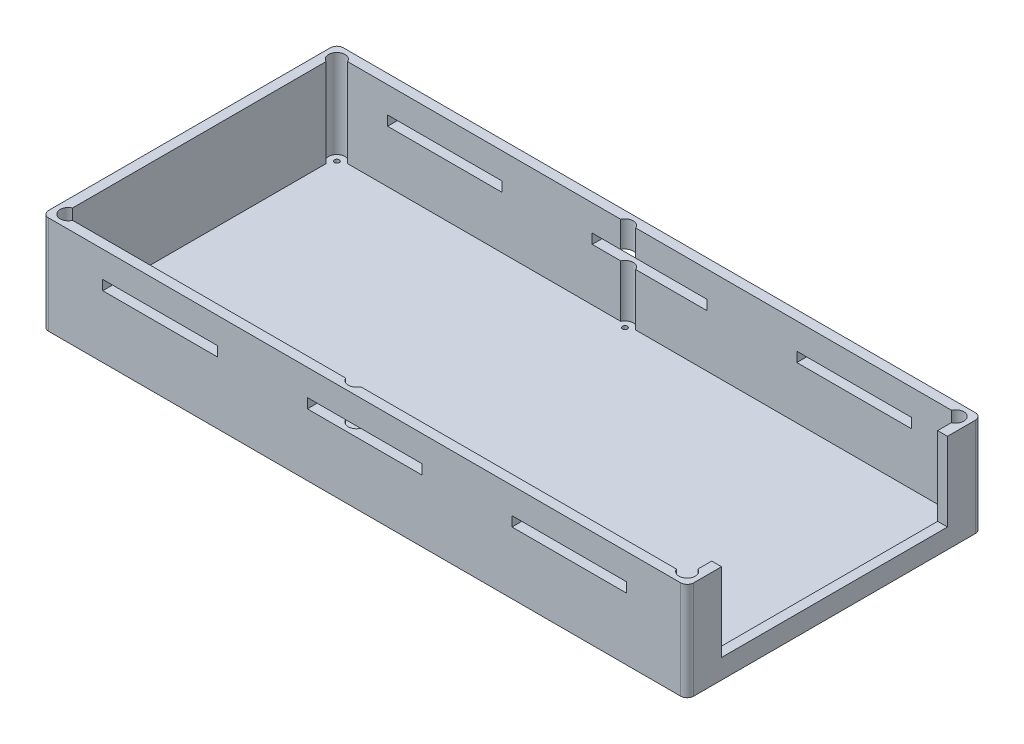
from build123d import *

# Parameters (mm, degrees)
SKETCH2_W               = 197
SKETCH2_H               = 90
BOSS_EXTRUDE1_DEPTH     = 21
SHELL1_T                = -2
SKETCH3_R               = 3.325
SKETCH3_R_2             = 1.325
BOSS_EXTRUDE2_DEPTH     = 2
SKETCH6_R               = 1.325
CUT_EXTRUDE2_DEPTH      = 3
BOSS_EXTRUDE3_DEPTH     = 19
SKETCH10_W              = 3
SKETCH10_H              = 12
CUT_EXTRUDE5_DEPTH      = 19
SKETCH12_W              = 29.592043876
SKETCH12_H              = 2
CUT_EXTRUDE6_DEPTH      = 10
CUT_EXTRUDE6_DEPTH_BACK = 73
CUT_EXTRUDE8_DEPTH      = 10
FILLET1_R               = 2
SKETCH7_R               = 6
CUT_EXTRUDE9_DEPTH      = 10
BOSS_EXTRUDE4_DEPTH     = 24
SKETCH18_W              = 191
SKETCH18_H              = 84
CUT_EXTRUDE10_DEPTH     = 21
BOSS_EXTRUDE5_DEPTH     = 19
SKETCH22_R              = 0.75
CUT_EXTRUDE11_DEPTH     = 44
SKETCH23_R              = 2
CUT_EXTRUDE12_DEPTH     = 22
SKETCH24_W              = 197
SKETCH24_H              = 24
CUT_EXTRUDE13_DEPTH     = 91
SKETCH25_R              = 0.75
BOSS_EXTRUDE9_DEPTH     = 28
BOSS_EXTRUDE10_START    = -2
BOSS_EXTRUDE10_DEPTH    = 2
BOSS_EXTRUDE11_DEPTH    = 30
SKETCH28_W              = 191
SKETCH28_H              = 84
CUT_EXTRUDE14_DEPTH     = 27
SKETCH29_R              = 0.75
CUT_EXTRUDE15_DEPTH     = 78
SKETCH30_W              = 197
SKETCH30_H              = 49
CUT_EXTRUDE16_DEPTH     = 91
SKETCH31_W              = 69
SKETCH31_H              = 24
CUT_EXTRUDE17_DEPTH     = 10
SKETCH32_R              = 2.5
CUT_EXTRUDE18_DEPTH     = 28
SKETCH33_W              = 35
SKETCH33_H              = 3
CUT_EXTRUDE19_DEPTH     = 91


with BuildPart() as part:
    # Sketch2 → Boss-Extrude1 (new body)
    with BuildSketch(Plane(origin=(0, 0, 0), x_dir=(1, 0, 0), z_dir=(0, 1, 0))):
        with Locations((98.5, 45)):
            Rectangle(SKETCH2_W, SKETCH2_H)
    extrude(amount=BOSS_EXTRUDE1_DEPTH)

    # Shell1
    shell1_openings = [part.faces().sort_by_distance(p)[0] for p in [
        (98.5, 21, -45),
    ]]
    offset(amount=SHELL1_T, openings=shell1_openings, kind=Kind.INTERSECTION)

    # Sketch3 → Boss-Extrude2 (add)
    with BuildSketch(Plane(origin=(0.486650368, 2, 38.670182975), x_dir=(1, 0, 0), z_dir=(0, 1, 0))):
        with Locations((118.948969004, 54.089521182)):
            Circle(SKETCH3_R)
        with Locations((118.948969004, 54.089521182)):
            Circle(SKETCH3_R_2, mode=Mode.SUBTRACT)
        with Locations((95.898969004, 54.089521182)):
            Circle(SKETCH3_R)
        with Locations((95.898969004, 54.089521182)):
            Circle(SKETCH3_R_2, mode=Mode.SUBTRACT)
        with Locations((95.898969004, 112.139521182)):
            Circle(SKETCH3_R)
        with Locations((95.898969004, 112.139521182)):
            Circle(SKETCH3_R_2, mode=Mode.SUBTRACT)
        with Locations((118.948969004, 112.139521182)):
            Circle(SKETCH3_R)
        with Locations((118.948969004, 112.139521182)):
            Circle(SKETCH3_R_2, mode=Mode.SUBTRACT)
    extrude(amount=BOSS_EXTRUDE2_DEPTH)

    # Sketch6 → Cut-Extrude2 (cut, through all)
    with BuildSketch(Plane(origin=(0, 2, 0), x_dir=(1, 0, 0), z_dir=(0, 1, 0))):
        with Locations((96.385619372, 73.469338207)):
            Circle(SKETCH6_R)
        with Locations((119.435619372, 73.469338207)):
            Circle(SKETCH6_R)
        with Locations((119.435619372, 15.419338207)):
            Circle(SKETCH6_R)
        with Locations((96.385619372, 15.419338207)):
            Circle(SKETCH6_R)
    extrude(amount=-CUT_EXTRUDE2_DEPTH, mode=Mode.SUBTRACT)

    # Sketch8 → Boss-Extrude3 (add)
    with BuildSketch(Plane(origin=(0, 2, 0), x_dir=(1, 0, 0), z_dir=(0, 1, 0))):
        Polygon((2, 28), (87, 28), (87, 87), (2, 87), (2, 90), (90, 90), (90, 25), (2, 25), align=None)
    extrude(amount=BOSS_EXTRUDE3_DEPTH)

    # Sketch10 → Cut-Extrude5 (cut)
    with BuildSketch(Plane(origin=(0, 21, 0), x_dir=(1, 0, 0), z_dir=(0, 1, 0))):
        with Locations((88.5, 57.5)):
            Rectangle(SKETCH10_W, SKETCH10_H)
    extrude(amount=-CUT_EXTRUDE5_DEPTH, mode=Mode.SUBTRACT)

    # Sketch12 → Cut-Extrude6 (cut, two sides)
    with BuildSketch(Plane(origin=(0, 0, -75), x_dir=(-1, 0, 0), z_dir=(0, 0, -1))) as cut_extrude6_sk:
        with Locations((-42.979341868, 13.109706)):
            Rectangle(SKETCH12_W, SKETCH12_H)
        with Locations((-42.979341868, 8.109706)):
            Rectangle(SKETCH12_W, SKETCH12_H)
    extrude(amount=CUT_EXTRUDE6_DEPTH, mode=Mode.SUBTRACT)
    extrude(cut_extrude6_sk.sketch, amount=-CUT_EXTRUDE6_DEPTH_BACK, mode=Mode.SUBTRACT)

    # Sketch16 → Cut-Extrude8 (cut)
    with BuildSketch(Plane(origin=(197, 0, 0), x_dir=(0, 0, -1), z_dir=(1, 0, 0))):
        with BuildLine():
            Line((48, 14.235547834), (48, 21))
            Line((48, 21), (42, 21))
            Line((42, 21), (42, 14.235547834))
            ThreePointArc((42, 14.235547834), (45, 11.235547834), (48, 14.235547834))
        make_face()
    extrude(amount=-CUT_EXTRUDE8_DEPTH, mode=Mode.SUBTRACT)

    # Fillet1
    fillet1_edges = [part.edges().sort_by_distance(p)[0] for p in [
        (98.5, 0, -90),
        (197, 0, -45),
        (98.5, 0, 0),
        (0, 0, -45),
        (0, 10.5, -90),
        (197, 10.5, -90),
        (197, 10.5, 0),
        (0, 10.5, 0),
    ]]
    fillet(fillet1_edges, radius=FILLET1_R)

    # Sketch7 → Cut-Extrude9 (cut)
    with BuildSketch(Plane.ZY):
        with Locations((-57.5, 13.5)):
            Circle(SKETCH7_R)
    extrude(amount=-CUT_EXTRUDE9_DEPTH, mode=Mode.SUBTRACT)

    # Sketch17 → Boss-Extrude4 (add)
    with BuildSketch(Plane(origin=(0, 21, 0), x_dir=(1, 0, 0), z_dir=(0, 1, 0))):
        with BuildLine():
            Line((197, 48), (197, 42))
            Line((197, 42), (197, 2))
            ThreePointArc((197, 2), (196.414213562, 0.585786438), (195, 0))
            Line((195, 0), (2, 0))
            ThreePointArc((2, 0), (0.585786438, 0.585786438), (0, 2))
            Line((0, 2), (0, 88))
            ThreePointArc((0, 88), (0.585786438, 89.414213562), (2, 90))
            Line((2, 90), (195, 90))
            ThreePointArc((195, 90), (196.414213562, 89.414213562), (197, 88))
            Line((197, 88), (197, 48))
        make_face()
    extrude(amount=BOSS_EXTRUDE4_DEPTH)

    # Sketch18 → Cut-Extrude10 (cut)
    with BuildSketch(Plane(origin=(0, 45, 0), x_dir=(1, 0, 0), z_dir=(0, 1, 0))):
        with Locations((98.5, 45)):
            Rectangle(SKETCH18_W, SKETCH18_H)
    extrude(amount=-CUT_EXTRUDE10_DEPTH, mode=Mode.SUBTRACT)

    # Sketch19 → Boss-Extrude5 (add)
    with BuildSketch(Plane(origin=(0, 2, 0), x_dir=(1, 0, 0), z_dir=(0, 1, 0))):
        with BuildLine():
            Line((193, 88), (195, 88))
            Line((195, 88), (195, 84))
            Line((195, 84), (193, 84))
            ThreePointArc((193, 84), (191.585786438, 84.585786438), (191, 86))
            Line((191, 86), (191, 88))
            Line((191, 88), (193, 88))
        make_face()
        with BuildLine():
            Line((191, 2), (193, 2))
            Line((193, 2), (195, 2))
            Line((195, 2), (195, 6))
            Line((195, 6), (193, 6))
            ThreePointArc((193, 6), (191.585786438, 5.414213562), (191, 4))
            Line((191, 4), (191, 2))
        make_face()
        with BuildLine():
            Line((94, 4), (94, 2))
            Line((94, 2), (90, 2))
            Line((90, 2), (90, 4))
            ThreePointArc((90, 4), (92, 6), (94, 4))
        make_face()
        with BuildLine():
            Line((92, 84), (90, 84))
            Line((90, 84), (90, 88))
            Line((90, 88), (94, 88))
            Line((94, 88), (94, 86))
            ThreePointArc((94, 86), (93.414213562, 84.585786438), (92, 84))
        make_face()
        with BuildLine():
            Line((2, 88), (2, 84))
            Line((2, 84), (4, 84))
            ThreePointArc((4, 84), (5.414213562, 84.585786438), (6, 86))
            Line((6, 86), (6, 88))
            Line((6, 88), (2, 88))
        make_face()
        with BuildLine():
            Line((6, 4), (6, 2))
            Line((6, 2), (2, 2))
            Line((2, 2), (2, 6))
            Line((2, 6), (4, 6))
            ThreePointArc((4, 6), (5.414213562, 5.414213562), (6, 4))
        make_face()
    extrude(amount=BOSS_EXTRUDE5_DEPTH)

    # Sketch22 → Cut-Extrude11 (cut, through all)
    with BuildSketch(Plane(origin=(0, 2, 0), x_dir=(1, 0, 0), z_dir=(0, 1, 0))):
        with Locations((4, 4)):
            Circle(SKETCH22_R)
        with Locations((4, 86)):
            Circle(SKETCH22_R)
        with Locations((92, 86)):
            Circle(SKETCH22_R)
        with Locations((193, 86)):
            Circle(SKETCH22_R)
        with Locations((193, 4)):
            Circle(SKETCH22_R)
        with Locations((92, 4)):
            Circle(SKETCH22_R)
    extrude(amount=CUT_EXTRUDE11_DEPTH, mode=Mode.SUBTRACT)

    # Sketch23 → Cut-Extrude12 (cut, through all)
    with BuildSketch(Plane(origin=(0, 24, 0), x_dir=(1, 0, 0), z_dir=(0, 1, 0))):
        with Locations((92, 4)):
            Circle(SKETCH23_R)
        with Locations((4, 4)):
            Circle(SKETCH23_R)
        with Locations((4, 86)):
            Circle(SKETCH23_R)
        with Locations((92, 86)):
            Circle(SKETCH23_R)
        with Locations((193, 86)):
            Circle(SKETCH23_R)
        with Locations((181, 4)):
            Circle(SKETCH23_R)
    extrude(amount=CUT_EXTRUDE12_DEPTH, mode=Mode.SUBTRACT)

    # Sketch24 → Cut-Extrude13 (cut, through all)
    with BuildSketch(Plane.XY):
        with Locations((98.5, 33)):
            Rectangle(SKETCH24_W, SKETCH24_H)
    extrude(amount=-CUT_EXTRUDE13_DEPTH, mode=Mode.SUBTRACT)

    # Sketch25 → Boss-Extrude9 (add)
    with BuildSketch(Plane(origin=(0, 21, 0), x_dir=(1, 0, 0), z_dir=(0, 1, 0))):
        with BuildLine():
            Line((197, 42), (197, 48))
            Line((197, 48), (197, 88))
            ThreePointArc((197, 88), (196.414213562, 89.414213562), (195, 90))
            Line((195, 90), (2, 90))
            ThreePointArc((2, 90), (0.585786438, 89.414213562), (0, 88))
            Line((0, 88), (0, 2))
            ThreePointArc((0, 2), (0.585786438, 0.585786438), (2, 0))
            Line((2, 0), (195, 0))
            ThreePointArc((195, 0), (196.414213562, 0.585786438), (197, 2))
            Line((197, 2), (197, 42))
        make_face()
        with Locations((4, 4)):
            Circle(SKETCH25_R, mode=Mode.SUBTRACT)
        with Locations((4, 86)):
            Circle(SKETCH25_R, mode=Mode.SUBTRACT)
        with Locations((92, 86)):
            Circle(SKETCH25_R, mode=Mode.SUBTRACT)
        with Locations((193, 86)):
            Circle(SKETCH25_R, mode=Mode.SUBTRACT)
        with Locations((193, 4)):
            Circle(SKETCH25_R, mode=Mode.SUBTRACT)
        with Locations((92, 4)):
            Circle(SKETCH25_R, mode=Mode.SUBTRACT)
        with BuildLine():
            Line((2, 25), (2, 28))
            Line((2, 28), (2, 84))
            Line((2, 84), (4, 84))
            ThreePointArc((4, 84), (5.414213562, 84.585786438), (6, 86))
            Line((6, 86), (6, 87))
            Line((6, 87), (87, 87))
            Line((87, 87), (90, 87))
            Line((90, 87), (90, 84))
            Line((90, 84), (92, 84))
            ThreePointArc((92, 84), (93.414213562, 84.585786438), (94, 86))
            Line((94, 86), (94, 88))
            Line((94, 88), (191, 88))
            Line((191, 88), (191, 86))
            ThreePointArc((191, 86), (191.585786438, 84.585786438), (193, 84))
            Line((193, 84), (195, 84))
            Line((195, 84), (195, 48))
            Line((195, 48), (195, 42))
            Line((195, 42), (195, 6))
            Line((195, 6), (193, 6))
            ThreePointArc((193, 6), (191.585786438, 5.414213562), (191, 4))
            Line((191, 4), (191, 2))
            Line((191, 2), (94, 2))
            Line((94, 2), (94, 4))
            ThreePointArc((94, 4), (92, 6), (90, 4))
            Line((90, 4), (90, 2))
            Line((90, 2), (6, 2))
            Line((6, 2), (6, 4))
            ThreePointArc((6, 4), (5.414213562, 5.414213562), (4, 6))
            Line((4, 6), (2, 6))
            Line((2, 6), (2, 25))
        make_face(mode=Mode.SUBTRACT)
    extrude(amount=BOSS_EXTRUDE9_DEPTH)

    # Sketch26 → Boss-Extrude10 (add)
    with BuildSketch(Plane(origin=(197, 0, 0), x_dir=(0, 0, -1), z_dir=(1, 0, 0)).offset(BOSS_EXTRUDE10_START)):
        with BuildLine():
            Line((48, 21), (42, 21))
            Line((42, 21), (42, 14.235547834))
            ThreePointArc((42, 14.235547834), (45, 11.235547834), (48, 14.235547834))
            Line((48, 14.235547834), (48, 21))
        make_face()
    extrude(amount=BOSS_EXTRUDE10_DEPTH)

    # Sketch27 → Boss-Extrude11 (add)
    with BuildSketch(Plane(origin=(0, 49, 0), x_dir=(1, 0, 0), z_dir=(0, 1, 0))):
        with BuildLine():
            Line((197, 2), (197, 88))
            ThreePointArc((197, 88), (196.414213562, 89.414213562), (195, 90))
            Line((195, 90), (2, 90))
            ThreePointArc((2, 90), (0.585786438, 89.414213562), (0, 88))
            Line((0, 88), (0, 2))
            ThreePointArc((0, 2), (0.585786438, 0.585786438), (2, 0))
            Line((2, 0), (195, 0))
            ThreePointArc((195, 0), (196.414213562, 0.585786438), (197, 2))
        make_face()
    extrude(amount=BOSS_EXTRUDE11_DEPTH)

    # Sketch28 → Cut-Extrude14 (cut)
    with BuildSketch(Plane(origin=(0, 79, 0), x_dir=(1, 0, 0), z_dir=(0, 1, 0))):
        with Locations((98.5, 45)):
            Rectangle(SKETCH28_W, SKETCH28_H)
    extrude(amount=-CUT_EXTRUDE14_DEPTH, mode=Mode.SUBTRACT)

    # Sketch29 → Cut-Extrude15 (cut, through all)
    with BuildSketch(Plane(origin=(0, 2, 0), x_dir=(1, 0, 0), z_dir=(0, 1, 0))):
        with Locations((4, 4)):
            Circle(SKETCH29_R)
        with Locations((4, 86)):
            Circle(SKETCH29_R)
        with Locations((193, 86)):
            Circle(SKETCH29_R)
        with Locations((193, 4)):
            Circle(SKETCH29_R)
        with Locations((92, 4)):
            Circle(SKETCH29_R)
        with Locations((92, 86)):
            Circle(SKETCH29_R)
    extrude(amount=CUT_EXTRUDE15_DEPTH, mode=Mode.SUBTRACT)

    # Sketch30 → Cut-Extrude16 (cut, through all)
    with BuildSketch(Plane.XY):
        with Locations((98.5, 24.5)):
            Rectangle(SKETCH30_W, SKETCH30_H)
    extrude(amount=-CUT_EXTRUDE16_DEPTH, mode=Mode.SUBTRACT)

    # Sketch31 → Cut-Extrude17 (cut)
    with BuildSketch(Plane(origin=(197, 0, 0), x_dir=(0, 0, -1), z_dir=(1, 0, 0))):
        with Locations((45, 67)):
            Rectangle(SKETCH31_W, SKETCH31_H)
    extrude(amount=-CUT_EXTRUDE17_DEPTH, mode=Mode.SUBTRACT)

    # Sketch32 → Cut-Extrude18 (cut, through all)
    with BuildSketch(Plane(origin=(0, 52, 0), x_dir=(1, 0, 0), z_dir=(0, 1, 0))):
        with Locations((4, 4)):
            Circle(SKETCH32_R)
        with Locations((4, 86)):
            Circle(SKETCH32_R)
        with Locations((92, 86)):
            Circle(SKETCH32_R)
        with Locations((193, 86)):
            Circle(SKETCH32_R)
        with Locations((193, 4)):
            Circle(SKETCH32_R)
        with Locations((92, 4)):
            Circle(SKETCH32_R)
    extrude(amount=CUT_EXTRUDE18_DEPTH, mode=Mode.SUBTRACT)

    # Sketch33 → Cut-Extrude19 (cut, through all)
    with BuildSketch(Plane.XY):
        with Locations((36, 69.5)):
            Rectangle(SKETCH33_W, SKETCH33_H)
        with Locations((98.5, 69.5)):
            Rectangle(SKETCH33_W, SKETCH33_H)
        with Locations((161, 69.5)):
            Rectangle(SKETCH33_W, SKETCH33_H)
    extrude(amount=-CUT_EXTRUDE19_DEPTH, mode=Mode.SUBTRACT)


solid = part.part
